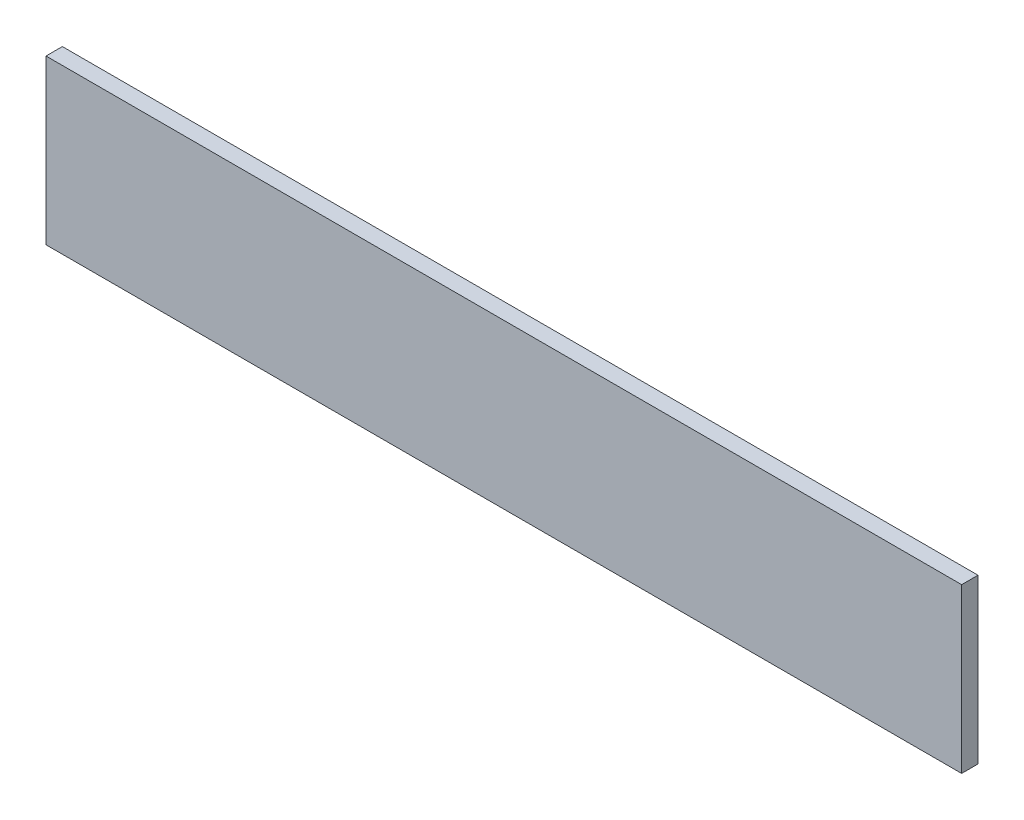
from build123d import *

# Parameters (mm, degrees)
SKETCH_1_W      = 280
SKETCH_1_H      = 50
EXTRUDE_1_DEPTH = 5


with BuildPart() as part:
    # 草图1 → 凸台-拉伸1 (new body)
    with BuildSketch(Plane.XY):
        Rectangle(SKETCH_1_W, SKETCH_1_H)
    extrude(amount=EXTRUDE_1_DEPTH)


solid = part.part
